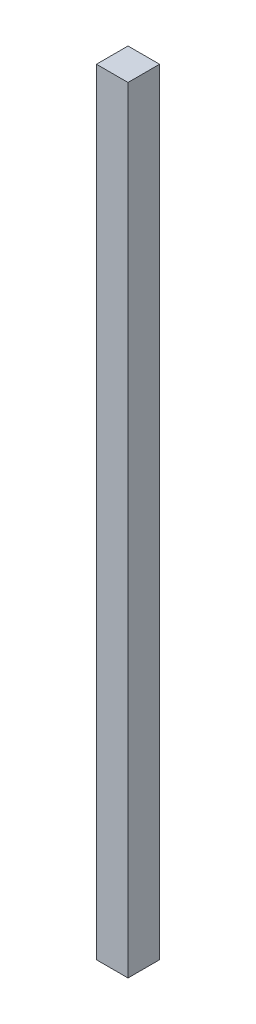
from build123d import *

# Parameters (mm, degrees)
ESQUISSE1_W        = 11.4
ESQUISSE1_H        = 11.4
BOSS_EXTRU_1_DEPTH = 280


with BuildPart() as part:
    # Esquisse1 → Boss.-Extru.1 (new body)
    with BuildSketch(Plane(origin=(0, 0, 0), x_dir=(1, 0, 0), z_dir=(0, 1, 0))):
        Rectangle(ESQUISSE1_W, ESQUISSE1_H)
    extrude(amount=BOSS_EXTRU_1_DEPTH)


solid = part.part
